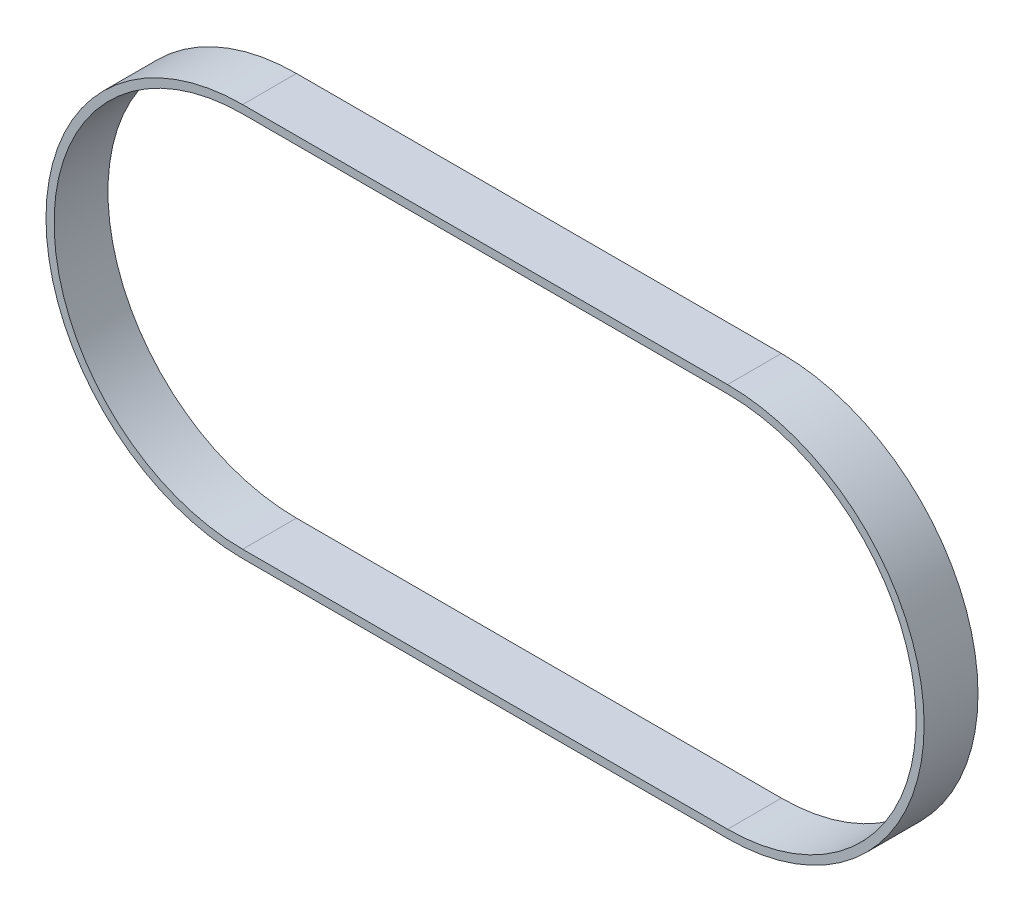
from build123d import *

# Parameters (mm, degrees)
BOSS_EXTRUDE1_DEPTH = 10


with BuildPart() as part:
    # Sketch1 → Boss-Extrude1 (new body)
    with BuildSketch(Plane.XY):
        with BuildLine():
            Line((-53.685033823, 30.553398058), (36.359223301, 30.553398058))
            ThreePointArc((36.359223301, 30.553398058), (72.859223301, -5.946601942), (36.359223301, -42.446601942))
            Line((36.359223301, -42.446601942), (-53.685033823, -42.446601942))
            ThreePointArc((-53.685033823, -42.446601942), (-90.185033823, -5.946601942), (-53.685033823, 30.553398058))
        make_face()
        with BuildLine():
            Line((-53.685033823, 29.053398058), (36.359223301, 29.053398058))
            ThreePointArc((36.359223301, 29.053398058), (71.359223301, -5.946601942), (36.359223301, -40.946601942))
            Line((36.359223301, -40.946601942), (-53.685033823, -40.946601942))
            ThreePointArc((-53.685033823, -40.946601942), (-88.685033823, -5.946601942), (-53.685033823, 29.053398058))
        make_face(mode=Mode.SUBTRACT)
    extrude(amount=BOSS_EXTRUDE1_DEPTH)


solid = part.part
